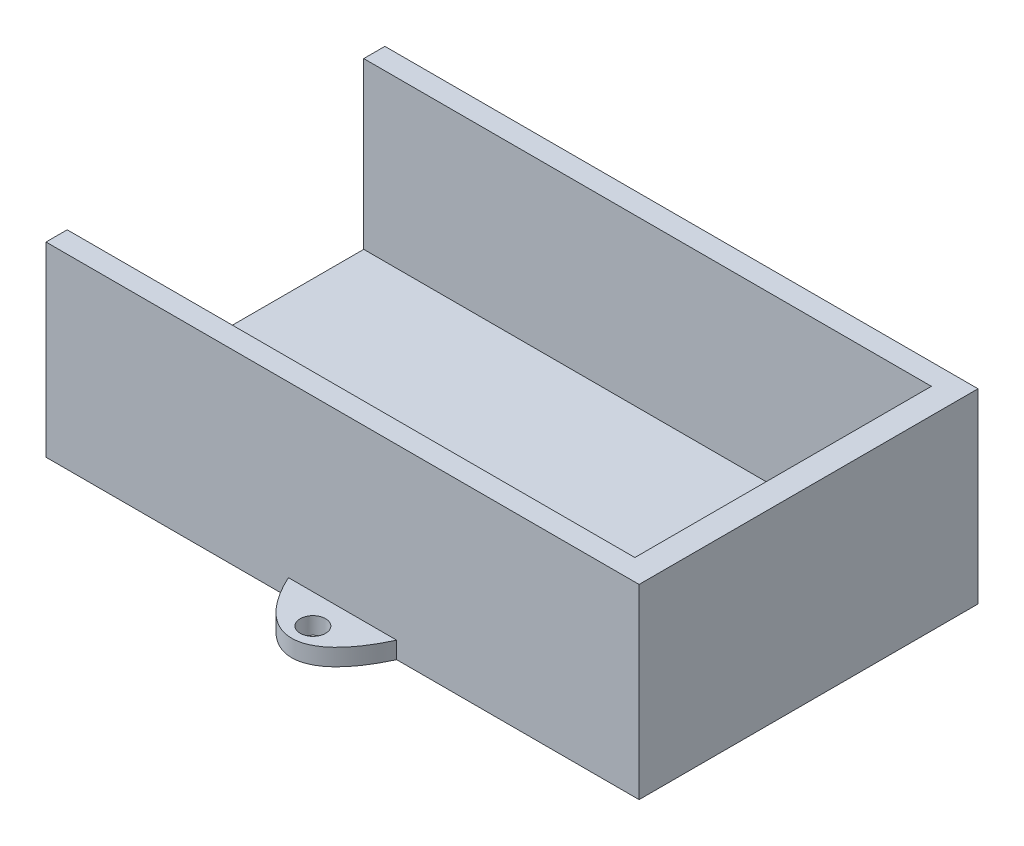
from build123d import *

# Parameters (mm, degrees)
IZIM1_W                     = 70
IZIM1_H                     = 40
Y_KSEKLIK_EKSTR_ZYON2_DEPTH = 25
IZIM2_W                     = 35
IZIM2_H                     = 20
KES_EKSTR_ZYON2_DEPTH       = 67
IZIM3_W                     = 70
IZIM3_H                     = 40
KES_EKSTR_ZYON3_DEPTH       = 3
IZIM4_RX                    = 26
IZIM4_RY                    = 10
Y_KSEKLIK_EKSTR_ZYON3_DEPTH = 2
IZIM5_R                     = 1.5
KES_EKSTR_ZYON5_DEPTH       = 16


with BuildPart() as part:
    # Çizim1 → Yükseklik-Ekstrüzyon2 (new body)
    with BuildSketch(Plane(origin=(0, 0, 0), x_dir=(1, 0, 0), z_dir=(0, 1, 0))):
        with Locations((-2.232631088, 6.981597522)):
            Rectangle(IZIM1_W, IZIM1_H)
    extrude(amount=Y_KSEKLIK_EKSTR_ZYON2_DEPTH)

    # Çizim2 → Kes-Ekstrüzyon2 (cut)
    with BuildSketch(Plane.ZY.offset(37.232631088)):
        with Locations((-6.981597522, 12.5)):
            Rectangle(IZIM2_W, IZIM2_H)
    extrude(amount=-KES_EKSTR_ZYON2_DEPTH, mode=Mode.SUBTRACT)

    # Çizim3 → Kes-Ekstrüzyon3 (cut)
    with BuildSketch(Plane(origin=(0, 25, 0), x_dir=(1, 0, 0), z_dir=(0, 1, 0))):
        with Locations((-2.232631088, 6.981597522)):
            Rectangle(IZIM3_W, IZIM3_H)
    extrude(amount=-KES_EKSTR_ZYON3_DEPTH, mode=Mode.SUBTRACT)

    # Çizim4 → Yükseklik-Ekstrüzyon3 (add)
    with BuildSketch(Plane.XZ):
        with Locations(Location((-2.232631088, -6.981597522), (0, 0, 90))):
            Ellipse(IZIM4_RX, IZIM4_RY)
    extrude(amount=-Y_KSEKLIK_EKSTR_ZYON3_DEPTH)

    # Çizim5 → Kes-Ekstrüzyon5 (cut)
    with BuildSketch(Plane(origin=(0, 2, 0), x_dir=(1, 0, 0), z_dir=(0, 1, 0))):
        with Locations((-2.232631088, -16.518402478)):
            Circle(IZIM5_R)
        with Locations((-2.232631088, 30.481597522)):
            Circle(IZIM5_R)
    extrude(amount=-KES_EKSTR_ZYON5_DEPTH, mode=Mode.SUBTRACT)


solid = part.part
